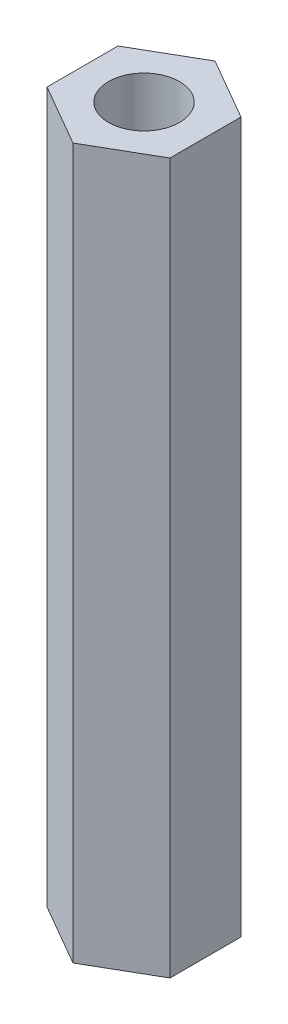
from build123d import *

# Parameters (mm, degrees)
ESQUISSE1_R      = 2.5
EXTRUSION1_DEPTH = 50


with BuildPart() as part:
    # Esquisse1 → Extrusion1 (new body)
    with BuildSketch(Plane(origin=(0, 0, 0), x_dir=(1, 0, 0), z_dir=(0, 1, 0))):
        Polygon((0, 5), (-4.330127019, 2.5), (-4.330127019, -2.5), (0, -5), (4.330127019, -2.5), (4.330127019, 2.5), align=None)
        Circle(ESQUISSE1_R, mode=Mode.SUBTRACT)
    extrude(amount=EXTRUSION1_DEPTH)


solid = part.part
